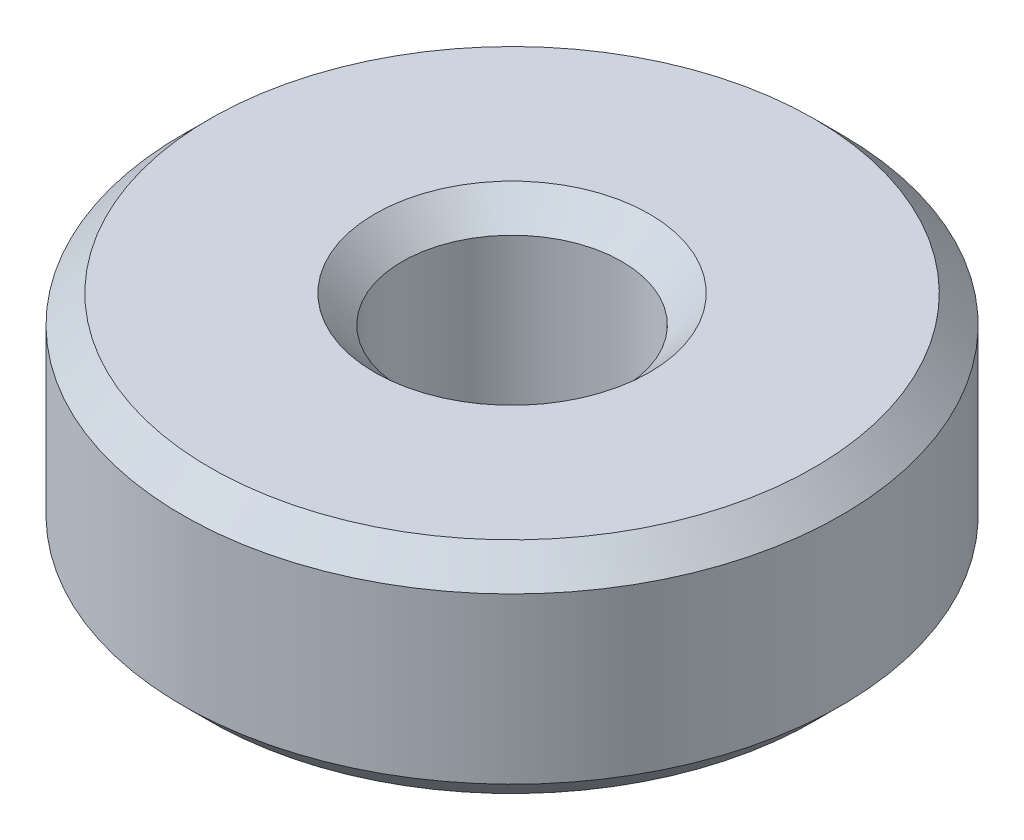
from build123d import *


with BuildPart() as part:
    # Sketch2 → Revolve1 (revolve)
    with BuildSketch(Plane.XY):
        Polygon((2.5, 0), (5.5, 0), (6, 0.5), (6, 3.5), (5.5, 4), (2.5, 4), (2, 3.5), (2, 0.5), align=None)
    revolve(axis=Axis((0, 0, 0), (0, 1, 0)))


solid = part.part
